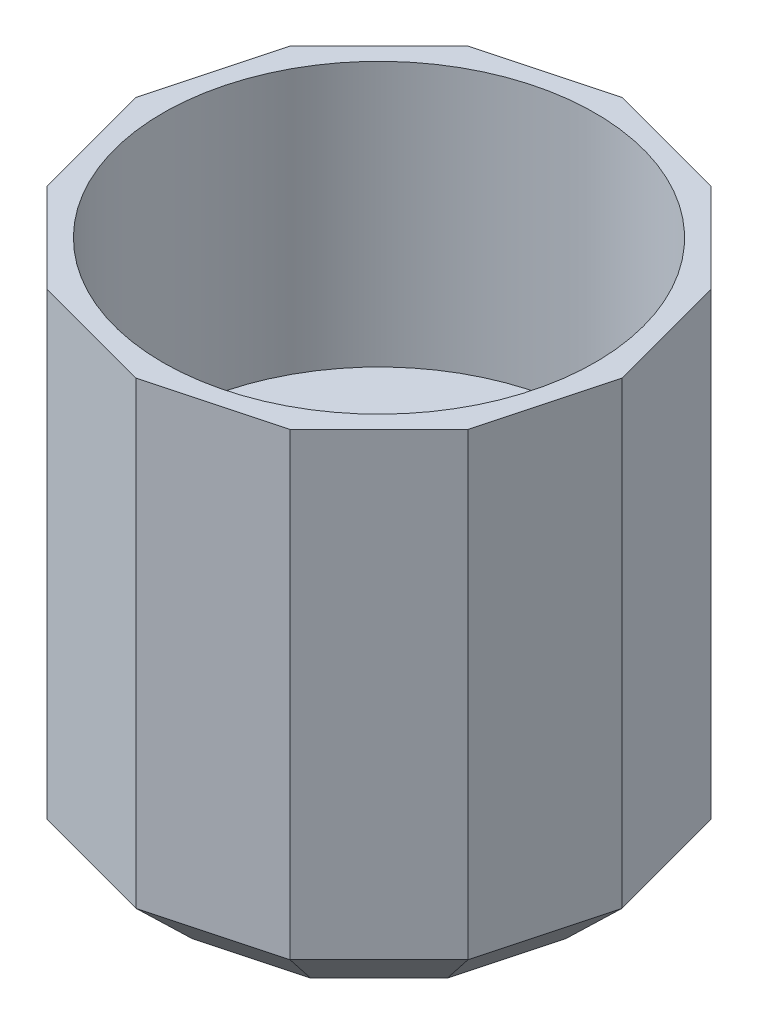
from build123d import *

# Parameters (mm, degrees)
BOSS_EXTRUDE1_DEPTH = 19
SKETCH2_R           = 8
CUT_EXTRUDE1_DEPTH  = 9.8
SKETCH3_R           = 3.05
CUT_EXTRUDE2_DEPTH  = 14
CHAMFER1_SIZE       = 2
SKETCH4_R           = 3.3
BOSS_EXTRUDE2_DEPTH = 3.2
BOSS_EXTRUDE3_DEPTH = 4
SKETCH7_R           = 3.05
BOSS_EXTRUDE4_DEPTH = 1
SKETCH8_R           = 3.05
BOSS_EXTRUDE5_DEPTH = 2


with BuildPart() as part:
    # Sketch1 → Boss-Extrude1 (new body)
    with BuildSketch(Plane(origin=(0, 0, 0), x_dir=(1, 0, 0), z_dir=(0, 1, 0))):
        Polygon((0, 9), (-4.5, 7.794228634), (-7.794228634, 4.5), (-9, 0), (-7.794228634, -4.5), (-4.5, -7.794228634), (0, -9), (4.5, -7.794228634), (7.794228634, -4.5), (9, 0), (7.794228634, 4.5), (4.5, 7.794228634), align=None)
    extrude(amount=BOSS_EXTRUDE1_DEPTH)

    # Sketch2 → Cut-Extrude1 (cut)
    with BuildSketch(Plane(origin=(0, 19, 0), x_dir=(1, 0, 0), z_dir=(0, 1, 0))):
        Circle(SKETCH2_R)
    extrude(amount=-CUT_EXTRUDE1_DEPTH, mode=Mode.SUBTRACT)

    # Sketch3 → Cut-Extrude2 (cut)
    with BuildSketch(Plane(origin=(0, 9.2, 0), x_dir=(1, 0, 0), z_dir=(0, 1, 0))):
        Circle(SKETCH3_R)
    extrude(amount=-CUT_EXTRUDE2_DEPTH, mode=Mode.SUBTRACT)

    # Chamfer1
    chamfer1_edges = [part.edges().sort_by_distance(p)[0] for p in [
        (6.147114317, 0, -6.147114317),
        (8.397114317, 0, -2.25),
        (8.397114317, 0, 2.25),
        (6.147114317, 0, 6.147114317),
        (2.25, 0, 8.397114317),
        (-2.25, 0, 8.397114317),
        (-6.147114317, 0, 6.147114317),
        (-8.397114317, 0, 2.25),
        (-8.397114317, 0, -2.25),
        (-6.147114317, 0, -6.147114317),
        (-2.25, 0, -8.397114317),
        (2.25, 0, -8.397114317),
    ]]
    chamfer(chamfer1_edges, length=CHAMFER1_SIZE)

    # Sketch4 → Boss-Extrude2 (add)
    with BuildSketch(Plane(origin=(0, 1, 0), x_dir=(1, 0, 0), z_dir=(0, 1, 0))):
        Circle(SKETCH4_R)
    extrude(amount=BOSS_EXTRUDE2_DEPTH)

    # Sketch6 → Boss-Extrude3 (add)
    with BuildSketch(Plane(origin=(0, 4.2, 0), x_dir=(1, 0, 0), z_dir=(0, 1, 0))):
        Polygon((-0.4, 0), (-0.4, 3.838549479), (0.4, 3.838549479), (0.4, -4.35363468), (-0.4, -4.35363468), align=None)
    extrude(amount=BOSS_EXTRUDE3_DEPTH)

    # Sketch7 → Boss-Extrude4 (add)
    with BuildSketch(Plane(origin=(0, 1, 0), x_dir=(-1, 0, 0), z_dir=(0, -1, 0))):
        Circle(SKETCH7_R)
    extrude(amount=BOSS_EXTRUDE4_DEPTH)

    # Sketch8 → Boss-Extrude5 (add)
    with BuildSketch(Plane(origin=(0, 4.2, 0), x_dir=(1, 0, 0), z_dir=(0, 1, 0))):
        Circle(SKETCH8_R)
    extrude(amount=BOSS_EXTRUDE5_DEPTH)


solid = part.part
